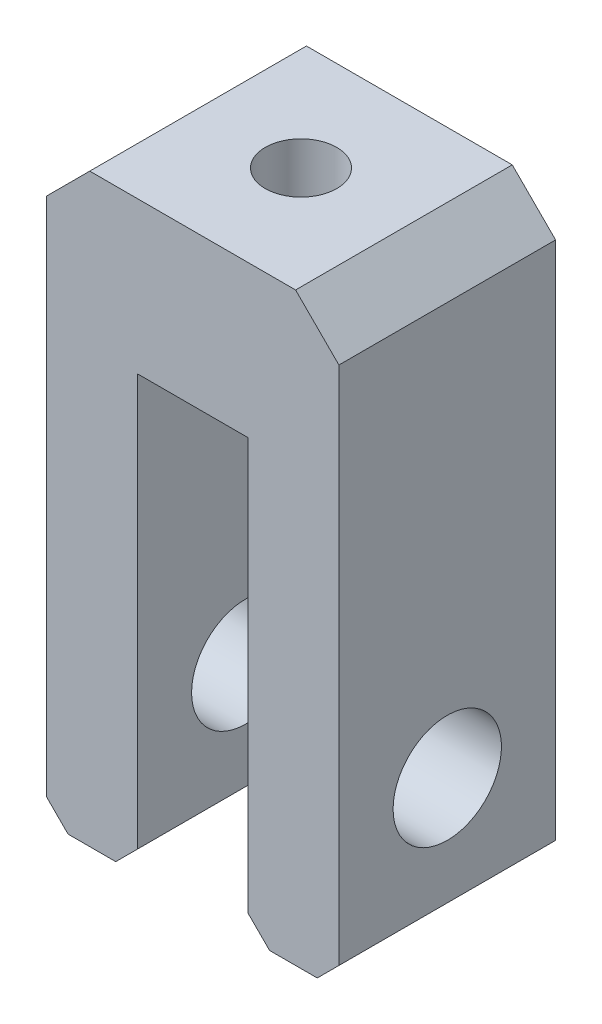
from build123d import *

# Parameters (mm, degrees)
EXTRUDE_1_DEPTH     = 10
SKETCH_2_R          = 2.5
CUT_EXTRUDE_1_DEPTH = 13.5
HOLE_WIZARD_M4_1_D  = 3.3
CHAMFER_1_SIZE      = 1
CHAMFER_2_SIZE      = 2


with BuildPart() as part:
    # 草图1 → 凸台-拉伸1 (new body)
    with BuildSketch(Plane.XY):
        Polygon((6.75, 0), (6.75, 27), (-6.75, 27), (-6.75, 0), (-2.55, 0), (-2.55, 20), (2.55, 20), (2.55, 0), align=None)
    extrude(amount=EXTRUDE_1_DEPTH)

    # 草图2 → 切除-拉伸1 (cut)
    with BuildSketch(Plane.ZY.offset(6.75)):
        with Locations((5, 6)):
            Circle(SKETCH_2_R)
    extrude(amount=-CUT_EXTRUDE_1_DEPTH, mode=Mode.SUBTRACT)

    # M4 螺纹孔1 (through all)
    with Locations(Plane(origin=(0, 27, 0), x_dir=(1, 0, 0), z_dir=(0, 1, 0))):
        with Locations((0, -5)):
            Hole(HOLE_WIZARD_M4_1_D / 2)

    # 倒角1
    chamfer_1_edges = [part.edges().sort_by_distance(p)[0] for p in [
        (6.75, 0, 5),
        (2.55, 0, 5),
        (-2.55, 0, 5),
        (-6.75, 0, 5),
    ]]
    chamfer(chamfer_1_edges, length=CHAMFER_1_SIZE)

    # 倒角2
    chamfer_2_edges = [part.edges().sort_by_distance(p)[0] for p in [
        (-6.75, 27, 5),
        (6.75, 27, 5),
    ]]
    chamfer(chamfer_2_edges, length=CHAMFER_2_SIZE)


solid = part.part
